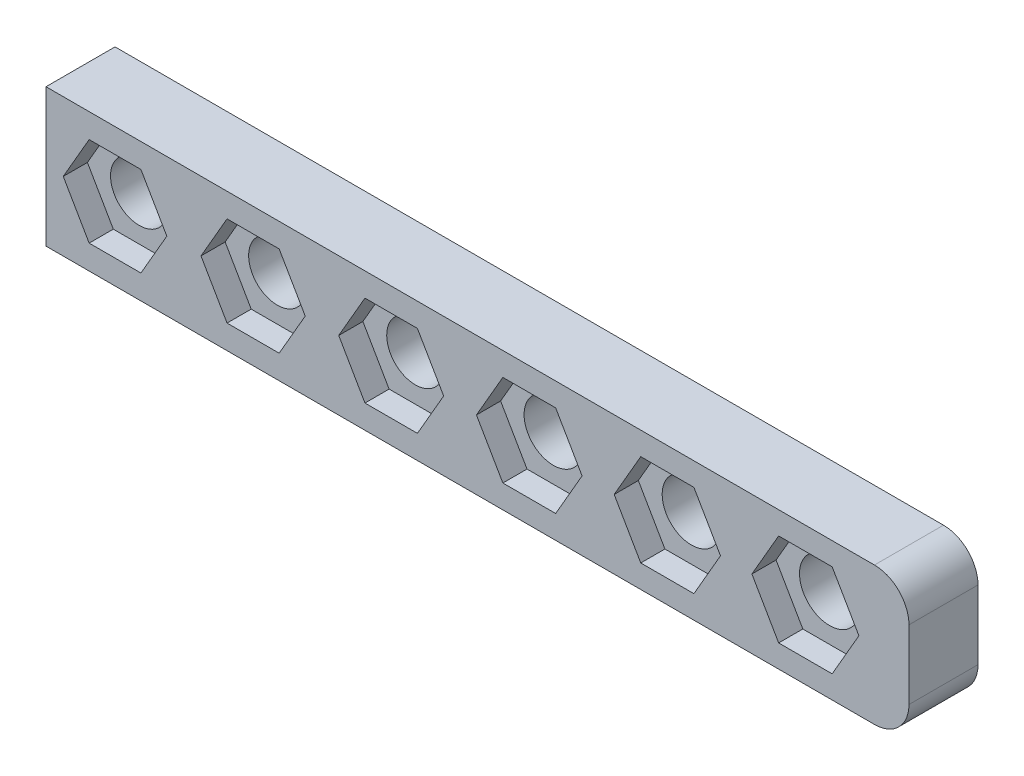
from build123d import *

# Parameters (mm, degrees)
SKETCH_1_W                  = 125
SKETCH_1_H                  = 20
EXTRUDE_1_DEPTH             = 10
CUT_EXTRUDE_1_DEPTH         = 3.5
CUT_EXTRUDE_2_DEPTH         = 3.5
CUT_EXTRUDE_3_DEPTH         = 3.5
CUT_EXTRUDE_4_DEPTH         = 3.5
CUT_EXTRUDE_5_DEPTH         = 3.5
CUT_EXTRUDE_6_DEPTH         = 3.5
HOLE_WIZARD_8_7_8_7_1_D     = 8.7
HOLE_WIZARD_8_7_8_7_1_DEPTH = 10
HOLE_WIZARD_8_5_8_5_1_D     = 8.5
HOLE_WIZARD_8_5_8_5_1_DEPTH = 10
HOLE_WIZARD_8_3_8_3_1_D     = 8.3
HOLE_WIZARD_8_3_8_3_1_DEPTH = 10
FILLET_1_R                  = 5


with BuildPart() as part:
    # 草图1 → 凸台-拉伸1 (new body)
    with BuildSketch(Plane(origin=(0, 0, 0), x_dir=(-1, 0, 0), z_dir=(0, 0, -1))):
        with Locations((-62.5, -116)):
            Rectangle(SKETCH_1_W, SKETCH_1_H)
    extrude(amount=-EXTRUDE_1_DEPTH)

    # 草图2 → 切除-拉伸1 (cut)
    with BuildSketch(Plane.XY.offset(10)):
        Polygon((93.85, -122.668395609), (97.7, -116), (93.85, -109.331604391), (86.15, -109.331604391), (82.3, -116), (86.15, -122.668395609), align=None)
    extrude(amount=-CUT_EXTRUDE_1_DEPTH, mode=Mode.SUBTRACT)

    # 草图3 → 切除-拉伸2 (cut)
    with BuildSketch(Plane.XY.offset(10)):
        Polygon((73.825, -122.625094339), (77.65, -116), (73.825, -109.374905661), (66.175, -109.374905661), (62.35, -116), (66.175, -122.625094339), align=None)
    extrude(amount=-CUT_EXTRUDE_2_DEPTH, mode=Mode.SUBTRACT)

    # 草图4 → 切除-拉伸3 (cut)
    with BuildSketch(Plane.XY.offset(10)):
        Polygon((53.8, -122.581793069), (57.6, -116), (53.8, -109.418206931), (46.2, -109.418206931), (42.4, -116), (46.2, -122.581793069), align=None)
    extrude(amount=-CUT_EXTRUDE_3_DEPTH, mode=Mode.SUBTRACT)

    # 草图5 → 切除-拉伸4 (cut)
    with BuildSketch(Plane.XY.offset(10)):
        Polygon((33.775, -122.538491799), (37.55, -116), (33.775, -109.461508201), (26.225, -109.461508201), (22.45, -116), (26.225, -122.538491799), align=None)
    extrude(amount=-CUT_EXTRUDE_4_DEPTH, mode=Mode.SUBTRACT)

    # 草图6 → 切除-拉伸5 (cut)
    with BuildSketch(Plane.XY.offset(10)):
        Polygon((13.75, -122.495190528), (17.5, -116), (13.75, -109.504809472), (6.25, -109.504809472), (2.5, -116), (6.25, -122.495190528), align=None)
    extrude(amount=-CUT_EXTRUDE_5_DEPTH, mode=Mode.SUBTRACT)

    # 草图7 → 切除-拉伸6 (cut)
    with BuildSketch(Plane.XY.offset(10)):
        Polygon((113.875, -122.711696879), (117.75, -116), (113.875, -109.288303121), (106.125, -109.288303121), (102.25, -116), (106.125, -122.711696879), align=None)
    extrude(amount=-CUT_EXTRUDE_6_DEPTH, mode=Mode.SUBTRACT)

    # Ø8.7 (8.7) 直径孔1
    with Locations(Plane(origin=(0, 0, 0), x_dir=(-1, 0, 0), z_dir=(0, 0, -1))):
        with Locations((-110, -116)):
            Hole(HOLE_WIZARD_8_7_8_7_1_D / 2, depth=HOLE_WIZARD_8_7_8_7_1_DEPTH)

    # Ø8.5 (8.5) 直径孔1
    with Locations(Plane(origin=(0, 0, 0), x_dir=(-1, 0, 0), z_dir=(0, 0, -1))):
        with Locations((-70, -116), (-90, -116)):
            Hole(HOLE_WIZARD_8_5_8_5_1_D / 2, depth=HOLE_WIZARD_8_5_8_5_1_DEPTH)

    # Ø8.3 (8.3) 直径孔1
    with Locations(Plane(origin=(0, 0, 0), x_dir=(-1, 0, 0), z_dir=(0, 0, -1))):
        with Locations((-30, -116), (-50, -116), (-10, -116)):
            Hole(HOLE_WIZARD_8_3_8_3_1_D / 2, depth=HOLE_WIZARD_8_3_8_3_1_DEPTH)

    # 圆角1
    fillet_1_edges = [part.edges().sort_by_distance(p)[0] for p in [
        (125, -126, 5),
        (125, -106, 5),
    ]]
    fillet(fillet_1_edges, radius=FILLET_1_R)


solid = part.part
